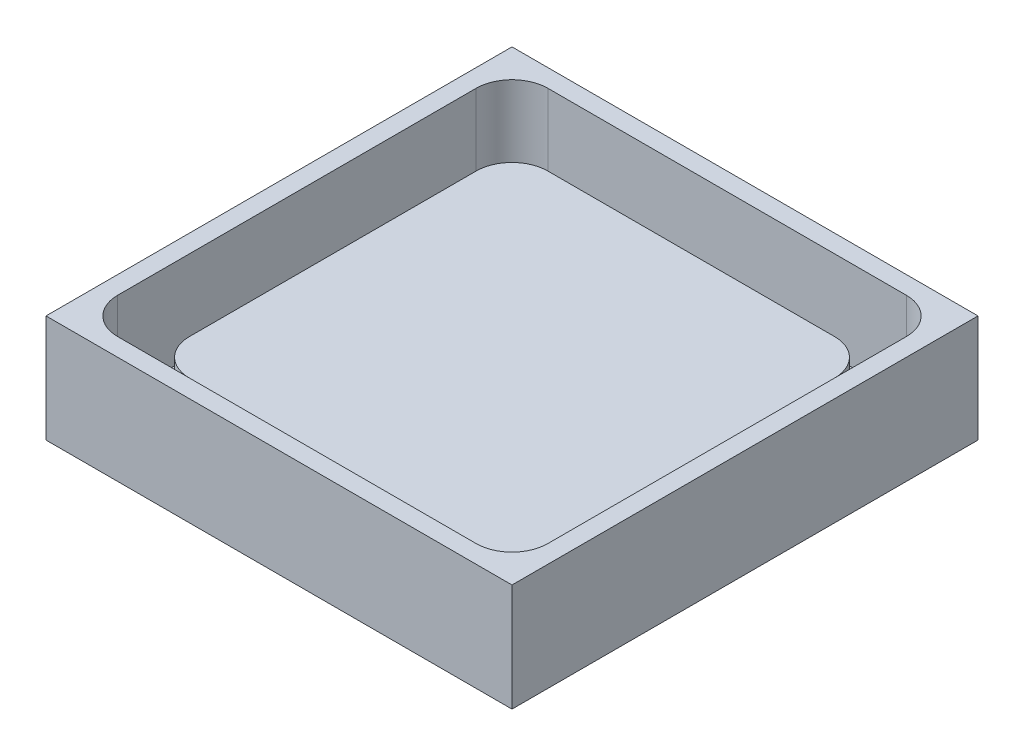
from build123d import *

# Parameters (mm, degrees)
SKETCH1_W           = 20
SKETCH1_H           = 20
BOSS_EXTRUDE1_DEPTH = 4
SKETCH2_W           = 24
SKETCH2_H           = 24
BOSS_EXTRUDE2_DEPTH = 1
SKETCH2_3_W         = 26
SKETCH2_3_H         = 26
SKETCH2_3_W_2       = 24
SKETCH2_3_H_2       = 24
BOSS_EXTRUDE3_DEPTH = 6
FILLET1_R           = 2
FILLET2_R           = 2


with BuildPart() as part:
    # Sketch1 → Boss-Extrude1 (new body)
    with BuildSketch(Plane(origin=(0, 0, 0), x_dir=(1, 0, 0), z_dir=(0, 1, 0))):
        Rectangle(SKETCH1_W, SKETCH1_H)
    extrude(amount=BOSS_EXTRUDE1_DEPTH)

    # Sketch2 → Boss-Extrude2 (add)
    with BuildSketch(Plane(origin=(0, 0, 0), x_dir=(1, 0, 0), z_dir=(0, 1, 0))):
        Rectangle(SKETCH2_W, SKETCH2_H)
    extrude(amount=BOSS_EXTRUDE2_DEPTH)

    # Sketch2_3 → Boss-Extrude3 (add)
    with BuildSketch(Plane(origin=(0, 0, 0), x_dir=(1, 0, 0), z_dir=(0, 1, 0))):
        Rectangle(SKETCH2_3_W, SKETCH2_3_H)
        Rectangle(SKETCH2_3_W_2, SKETCH2_3_H_2, mode=Mode.SUBTRACT)
    extrude(amount=BOSS_EXTRUDE3_DEPTH)

    # Fillet1
    fillet1_edges = [part.edges().sort_by_distance(p)[0] for p in [
        (-10, 2.5, 10),
        (10, 2.5, 10),
        (10, 2.5, -10),
        (-10, 2.5, -10),
    ]]
    fillet(fillet1_edges, radius=FILLET1_R)

    # Fillet2
    fillet2_edges = [part.edges().sort_by_distance(p)[0] for p in [
        (12, 3.5, 12),
        (-12, 3.5, 12),
        (12, 3.5, -12),
        (-12, 3.5, -12),
    ]]
    fillet(fillet2_edges, radius=FILLET2_R)


solid = part.part
